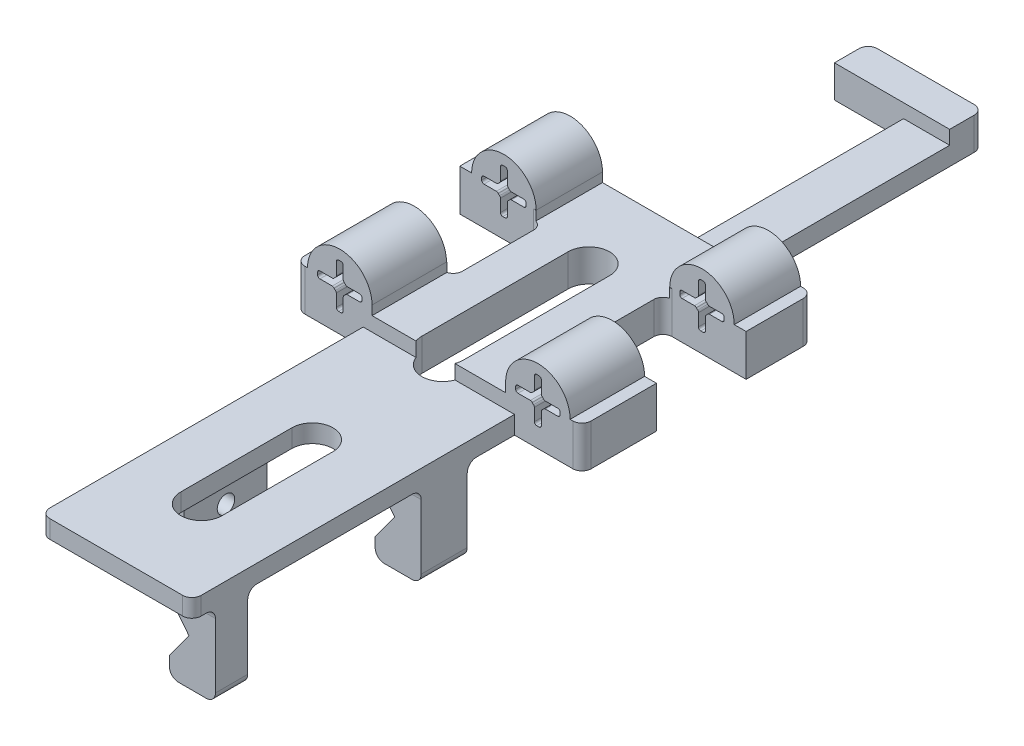
from build123d import *

# Parameters (mm, degrees)
EXTRUDE_1_DEPTH     = 50
SKETCH_3_W          = 67.092836977
SKETCH_3_H          = 19.45251838
CUT_EXTRUDE_1_DEPTH = 10
FILLET_1_R          = 2
CUT_EXTRUDE_2_DEPTH = 30
SKETCH_5_W          = 32.84020982
SKETCH_5_H          = 3.9
EXTRUDE_2_DEPTH     = 70
SKETCH_7_W          = 28.980294199
SKETCH_7_H          = 50
CUT_EXTRUDE_3_DEPTH = 12
SKETCH_10_W         = 6.123292798
SKETCH_10_H         = 18
EXTRUDE_4_DEPTH     = 18
FILLET_6_R          = 3
EXTRUDE_7_DEPTH     = 55
SKETCH_17_W         = 25
SKETCH_17_H         = 7.327182452
EXTRUDE_8_DEPTH     = 7
SKETCH_18_W         = 10
SKETCH_18_H         = 7
SKETCH_18_H_2       = 9.984274322
EXTRUDE_9_DEPTH     = 18
CUT_EXTRUDE_4_DEPTH = 60
FILLET_7_R          = 2
SKETCH_20_R         = 1.9
CUT_EXTRUDE_5_DEPTH = 13
FILLET_8_R          = 2
CUT_EXTRUDE_6_DEPTH = 13
FILLET_9_R          = 2
CUT_EXTRUDE_7_DEPTH = 13
FILLET_10_R         = 2


with BuildPart() as part:
    # Эскиз1 → Бобышка-Вытянуть1 (new body)
    with BuildSketch(Plane.XY):
        with BuildLine():
            Line((9.423236547, -5), (9.423236547, -10))
            Line((9.423236547, -10), (9.423236547, -14))
            Line((9.423236547, -14), (71.557057652, -14))
            Line((71.557057652, -14), (71.557057652, -10))
            Line((71.557057652, -10), (71.557057652, -5))
            Line((71.557057652, -5), (68.980294199, -5))
            ThreePointArc((68.980294199, -5), (61.980294199, 2), (54.980294199, -5))
            Line((54.980294199, -5), (26, -5))
            ThreePointArc((26, -5), (19, 2), (12, -5))
            Line((12, -5), (9.423236547, -5))
        make_face()
        with BuildLine():
            Line((20.624807681, -4.25), (23.317234975, -4.25))
            ThreePointArc((23.317234975, -4.25), (23.670788365, -4.396446609), (23.817234975, -4.75))
            Line((23.817234975, -4.75), (23.817234975, -5))
            Line((23.817234975, -5), (23.817234975, -5.25))
            ThreePointArc((23.817234975, -5.25), (23.670788365, -5.603553391), (23.317234975, -5.75))
            Line((23.317234975, -5.75), (20.624807681, -5.75))
            ThreePointArc((20.624807681, -5.75), (20.403944629, -5.801425021), (20.228513125, -5.945121951))
            ThreePointArc((20.228513125, -5.945121951), (20.096015511, -6.096015511), (19.945121951, -6.228513125))
            ThreePointArc((19.945121951, -6.228513125), (19.801425021, -6.403944629), (19.75, -6.624807681))
            Line((19.75, -6.624807681), (19.75, -9.317234975))
            ThreePointArc((19.75, -9.317234975), (19.603553391, -9.670788365), (19.25, -9.817234975))
            Line((19.25, -9.817234975), (19, -9.817234975))
            Line((19, -9.817234975), (18.75, -9.817234975))
            ThreePointArc((18.75, -9.817234975), (18.396446609, -9.670788365), (18.25, -9.317234975))
            Line((18.25, -9.317234975), (18.25, -6.624807681))
            ThreePointArc((18.25, -6.624807681), (18.198574979, -6.403944629), (18.054878049, -6.228513125))
            ThreePointArc((18.054878049, -6.228513125), (17.903984489, -6.096015511), (17.771486875, -5.945121951))
            ThreePointArc((17.771486875, -5.945121951), (17.596055371, -5.801425021), (17.375192319, -5.75))
            Line((17.375192319, -5.75), (14.682765025, -5.75))
            ThreePointArc((14.682765025, -5.75), (14.329211635, -5.603553391), (14.182765025, -5.25))
            Line((14.182765025, -5.25), (14.182765025, -5))
            Line((14.182765025, -5), (14.182765025, -4.75))
            ThreePointArc((14.182765025, -4.75), (14.329211635, -4.396446609), (14.682765025, -4.25))
            Line((14.682765025, -4.25), (17.375192319, -4.25))
            ThreePointArc((17.375192319, -4.25), (17.596055371, -4.198574979), (17.771486875, -4.054878049))
            ThreePointArc((17.771486875, -4.054878049), (17.903984489, -3.903984489), (18.054878049, -3.771486875))
            ThreePointArc((18.054878049, -3.771486875), (18.198574979, -3.596055371), (18.25, -3.375192319))
            Line((18.25, -3.375192319), (18.25, -0.682765025))
            ThreePointArc((18.25, -0.682765025), (18.396446609, -0.329211635), (18.75, -0.182765025))
            Line((18.75, -0.182765025), (19, -0.182765025))
            Line((19, -0.182765025), (19.25, -0.182765025))
            ThreePointArc((19.25, -0.182765025), (19.603553391, -0.329211635), (19.75, -0.682765025))
            Line((19.75, -0.682765025), (19.75, -3.375192319))
            ThreePointArc((19.75, -3.375192319), (19.801425021, -3.596055371), (19.945121951, -3.771486875))
            ThreePointArc((19.945121951, -3.771486875), (20.096015511, -3.903984489), (20.228513125, -4.054878049))
            ThreePointArc((20.228513125, -4.054878049), (20.403944629, -4.198574979), (20.624807681, -4.25))
        make_face(mode=Mode.SUBTRACT)
        with BuildLine():
            ThreePointArc((63.208807324, -4.054878049), (63.384238828, -4.198574979), (63.60510188, -4.25))
            Line((63.60510188, -4.25), (66.297529174, -4.25))
            ThreePointArc((66.297529174, -4.25), (66.651082564, -4.396446609), (66.797529174, -4.75))
            Line((66.797529174, -4.75), (66.797529174, -5))
            Line((66.797529174, -5), (66.797529174, -5.25))
            ThreePointArc((66.797529174, -5.25), (66.651082564, -5.603553391), (66.297529174, -5.75))
            Line((66.297529174, -5.75), (63.60510188, -5.75))
            ThreePointArc((63.60510188, -5.75), (63.384238828, -5.801425021), (63.208807324, -5.945121951))
            ThreePointArc((63.208807324, -5.945121951), (63.07630971, -6.096015511), (62.92541615, -6.228513125))
            ThreePointArc((62.92541615, -6.228513125), (62.78171922, -6.403944629), (62.730294199, -6.624807681))
            Line((62.730294199, -6.624807681), (62.730294199, -9.317234975))
            ThreePointArc((62.730294199, -9.317234975), (62.58384759, -9.670788365), (62.230294199, -9.817234975))
            Line((62.230294199, -9.817234975), (61.980294199, -9.817234975))
            Line((61.980294199, -9.817234975), (61.730294199, -9.817234975))
            ThreePointArc((61.730294199, -9.817234975), (61.376740808, -9.670788365), (61.230294199, -9.317234975))
            Line((61.230294199, -9.317234975), (61.230294199, -6.624807681))
            ThreePointArc((61.230294199, -6.624807681), (61.178869178, -6.403944629), (61.035172248, -6.228513125))
            ThreePointArc((61.035172248, -6.228513125), (60.884278688, -6.096015511), (60.751781074, -5.945121951))
            ThreePointArc((60.751781074, -5.945121951), (60.57634957, -5.801425021), (60.355486518, -5.75))
            Line((60.355486518, -5.75), (57.663059224, -5.75))
            ThreePointArc((57.663059224, -5.75), (57.309505834, -5.603553391), (57.163059224, -5.25))
            Line((57.163059224, -5.25), (57.163059224, -5))
            Line((57.163059224, -5), (57.163059224, -4.75))
            ThreePointArc((57.163059224, -4.75), (57.309505834, -4.396446609), (57.663059224, -4.25))
            Line((57.663059224, -4.25), (60.355486518, -4.25))
            ThreePointArc((60.355486518, -4.25), (60.57634957, -4.198574979), (60.751781074, -4.054878049))
            ThreePointArc((60.751781074, -4.054878049), (60.884278688, -3.903984489), (61.035172248, -3.771486875))
            ThreePointArc((61.035172248, -3.771486875), (61.178869178, -3.596055371), (61.230294199, -3.375192319))
            Line((61.230294199, -3.375192319), (61.230294199, -0.682765025))
            ThreePointArc((61.230294199, -0.682765025), (61.376740808, -0.329211635), (61.730294199, -0.182765025))
            Line((61.730294199, -0.182765025), (61.980294199, -0.182765025))
            Line((61.980294199, -0.182765025), (62.230294199, -0.182765025))
            ThreePointArc((62.230294199, -0.182765025), (62.58384759, -0.329211635), (62.730294199, -0.682765025))
            Line((62.730294199, -0.682765025), (62.730294199, -3.375192319))
            ThreePointArc((62.730294199, -3.375192319), (62.78171922, -3.596055371), (62.92541615, -3.771486875))
            ThreePointArc((62.92541615, -3.771486875), (63.07630971, -3.903984489), (63.208807324, -4.054878049))
        make_face(mode=Mode.SUBTRACT)
    extrude(amount=EXTRUDE_1_DEPTH)

    # Эскиз3 → Вырез-Вытянуть1 (cut)
    with BuildSketch(Plane(origin=(0, 5, 0), x_dir=(1, 0, 0), z_dir=(0, 1, 0))):
        with Locations((41.003987207, -24.119131243)):
            Rectangle(SKETCH_3_W, SKETCH_3_H)
    extrude(amount=-CUT_EXTRUDE_1_DEPTH, mode=Mode.SUBTRACT)

    # Скругление1
    fillet_1_edges = [part.edges().sort_by_distance(p)[0] for p in [
        (9.423236547, -9.5, 50),
        (71.557057652, -9.5, 50),
        (71.557057652, -9.5, 0),
        (9.423236547, -9.5, 0),
    ]]
    fillet(fillet_1_edges, radius=FILLET_1_R)

    # Эскиз4 → Вырез-Вытянуть2 (cut)
    with BuildSketch(Plane(origin=(0, 5, 0), x_dir=(1, 0, 0), z_dir=(0, 1, 0))):
        with BuildLine():
            Line((12, -14.392872053), (25.453701909, -14.392872053))
            ThreePointArc((25.453701909, -14.392872053), (26.867915472, -14.978658491), (27.453701909, -16.392872053))
            Line((27.453701909, -16.392872053), (27.453701909, -31.845390433))
            ThreePointArc((27.453701909, -31.845390433), (26.867915472, -33.259603995), (25.453701909, -33.845390433))
            Line((25.453701909, -33.845390433), (12, -33.845390433))
            Line((12, -33.845390433), (9.423236547, -33.845390433))
            Line((9.423236547, -33.845390433), (9.423236547, -14.392872053))
            Line((9.423236547, -14.392872053), (12, -14.392872053))
        make_face()
        with BuildLine():
            Line((71.557057652, -33.845390433), (68.980294199, -33.845390433))
            Line((68.980294199, -33.845390433), (55.52659229, -33.845390433))
            ThreePointArc((55.52659229, -33.845390433), (54.112378727, -33.259603995), (53.52659229, -31.845390433))
            Line((53.52659229, -31.845390433), (53.52659229, -16.392872053))
            ThreePointArc((53.52659229, -16.392872053), (54.112378727, -14.978658491), (55.52659229, -14.392872053))
            Line((55.52659229, -14.392872053), (68.980294199, -14.392872053))
            Line((68.980294199, -14.392872053), (71.557057652, -14.392872053))
            Line((71.557057652, -14.392872053), (71.557057652, -33.845390433))
        make_face()
    extrude(amount=-CUT_EXTRUDE_2_DEPTH, mode=Mode.SUBTRACT)

    # Эскиз5 → Бобышка-Вытянуть2 (add)
    with BuildSketch(Plane.XY.offset(50)):
        with Locations((40.499001364, -12.05)):
            Rectangle(SKETCH_5_W, SKETCH_5_H)
    extrude(amount=EXTRUDE_2_DEPTH)

    # Эскиз7 → Вырез-Вытянуть3 (cut)
    with BuildSketch(Plane(origin=(0, 5, 0), x_dir=(1, 0, 0), z_dir=(0, 1, 0))):
        with Locations((40.4901471, -25)):
            Rectangle(SKETCH_7_W, SKETCH_7_H)
    extrude(amount=-CUT_EXTRUDE_3_DEPTH, mode=Mode.SUBTRACT)

    # Эскиз10 → Бобышка-Вытянуть4 (add)
    with BuildSketch(Plane(origin=(0, -14, 0), x_dir=(-1, 0, 0), z_dir=(0, -1, 0))):
        with Locations((-27.140542853, -85.972684437)):
            Rectangle(SKETCH_10_W, SKETCH_10_H)
    extrude(amount=EXTRUDE_4_DEPTH)

    # Скругление6
    fillet_6_edges = [part.edges().sort_by_distance(p)[0] for p in [
        (27.140542853, -14, 94.972684437),
        (27.140542853, -14, 76.972684437),
        (30.202189252, -14, 85.972684437),
    ]]
    fillet(fillet_6_edges, radius=FILLET_6_R)

    # Эскиз15 → Бобышка-Вытянуть7 (add)
    with BuildSketch(Plane(origin=(0, 0, 0), x_dir=(-1, 0, 0), z_dir=(0, 0, -1))):
        Polygon((-53.655904349, -10), (-53.655904349, -14), (-49.655904349, -14), (-43.655904349, -14), (-43.655904349, -10), (-49.655904349, -10), align=None)
    extrude(amount=EXTRUDE_7_DEPTH)

    # Эскиз17 → Бобышка-Вытянуть8 (add)
    with BuildSketch(Plane.XZ.offset(14)):
        with Locations((41.155904349, -51.336408774)):
            Rectangle(SKETCH_17_W, SKETCH_17_H)
    extrude(amount=-EXTRUDE_8_DEPTH)

    # Эскиз18 → Бобышка-Вытянуть9 (add)
    with BuildSketch(Plane(origin=(0, -14, 0), x_dir=(-1, 0, 0), z_dir=(0, -1, 0))):
        with Locations((-51.919106274, -111.399557275)):
            Rectangle(SKETCH_18_W, SKETCH_18_H)
        with Locations((-51.919106274, -65.255303614)):
            Rectangle(SKETCH_18_W, SKETCH_18_H_2)
    extrude(amount=EXTRUDE_9_DEPTH)

    # Эскиз19 → Вырез-Вытянуть4 (cut)
    with BuildSketch(Plane.XY.offset(114.899557275)):
        Polygon((51.166261761, -22.096991658), (46.919106274, -16.788419259), (46.919106274, -27.943559029), align=None)
    extrude(amount=-CUT_EXTRUDE_4_DEPTH, mode=Mode.SUBTRACT)

    # Скругление7
    fillet_7_edges = [part.edges().sort_by_distance(p)[0] for p in [
        (51.919106274, -14, 114.899557275),
        (46.919106274, -14, 111.399557275),
        (51.919106274, -14, 107.899557275),
        (46.919106274, -14, 65.255303614),
        (51.919106274, -14, 60.263166453),
        (51.919106274, -14, 70.247440775),
    ]]
    fillet(fillet_7_edges, radius=FILLET_7_R)

    # Эскиз20 → Вырез-Вытянуть5 (cut)
    with BuildSketch(Plane.ZY.offset(-24.078896454)):
        with Locations((85.894256743, -22.362458589)):
            Circle(SKETCH_20_R)
    extrude(amount=-CUT_EXTRUDE_5_DEPTH, mode=Mode.SUBTRACT)

    # Скругление8
    fillet_8_edges = [part.edges().sort_by_distance(p)[0] for p in [
        (27.140542853, -32, 94.972684437),
        (27.140542853, -32, 76.972684437),
        (56.919106274, -32, 111.399557275),
        (46.919106274, -32, 111.399557275),
        (46.919106274, -32, 65.255303614),
        (56.919106274, -32, 65.255303614),
    ]]
    fillet(fillet_8_edges, radius=FILLET_8_R)

    # Эскиз21 → Вырез-Вытянуть6 (cut)
    with BuildSketch(Plane.XZ.offset(14)):
        with BuildLine():
            Line((35.273551739, 100.76510153), (35.273551739, 76.684498298))
            ThreePointArc((35.273551739, 76.684498298), (39.745442077, 72.21260796), (44.217332414, 76.684498298))
            Line((44.217332414, 76.684498298), (44.217332414, 100.76510153))
            ThreePointArc((44.217332414, 100.76510153), (39.745442077, 105.236991867), (35.273551739, 100.76510153))
        make_face()
    extrude(amount=-CUT_EXTRUDE_6_DEPTH, mode=Mode.SUBTRACT)

    # Скругление9
    fillet_9_edges = [part.edges().sort_by_distance(p)[0] for p in [
        (56.919106274, -12.05, 120),
        (24.078896454, -12.05, 120),
    ]]
    fillet(fillet_9_edges, radius=FILLET_9_R)

    # Эскиз22 → Вырез-Вытянуть7 (cut)
    with BuildSketch(Plane.XZ.offset(14)):
        with BuildLine():
            Line((35.265055807, 48.444967369), (35.265055807, 16.736762539))
            ThreePointArc((35.265055807, 16.736762539), (39.765055807, 12.236762539), (44.265055807, 16.736762539))
            Line((44.265055807, 16.736762539), (44.265055807, 48.444967369))
            ThreePointArc((44.265055807, 48.444967369), (39.765055807, 52.944967369), (35.265055807, 48.444967369))
        make_face()
    extrude(amount=-CUT_EXTRUDE_7_DEPTH, mode=Mode.SUBTRACT)

    # Скругление10
    fillet_10_edges = [part.edges().sort_by_distance(p)[0] for p in [
        (53.655904349, -10.5, -55),
        (28.655904349, -10.5, -55),
    ]]
    fillet(fillet_10_edges, radius=FILLET_10_R)


solid = part.part
